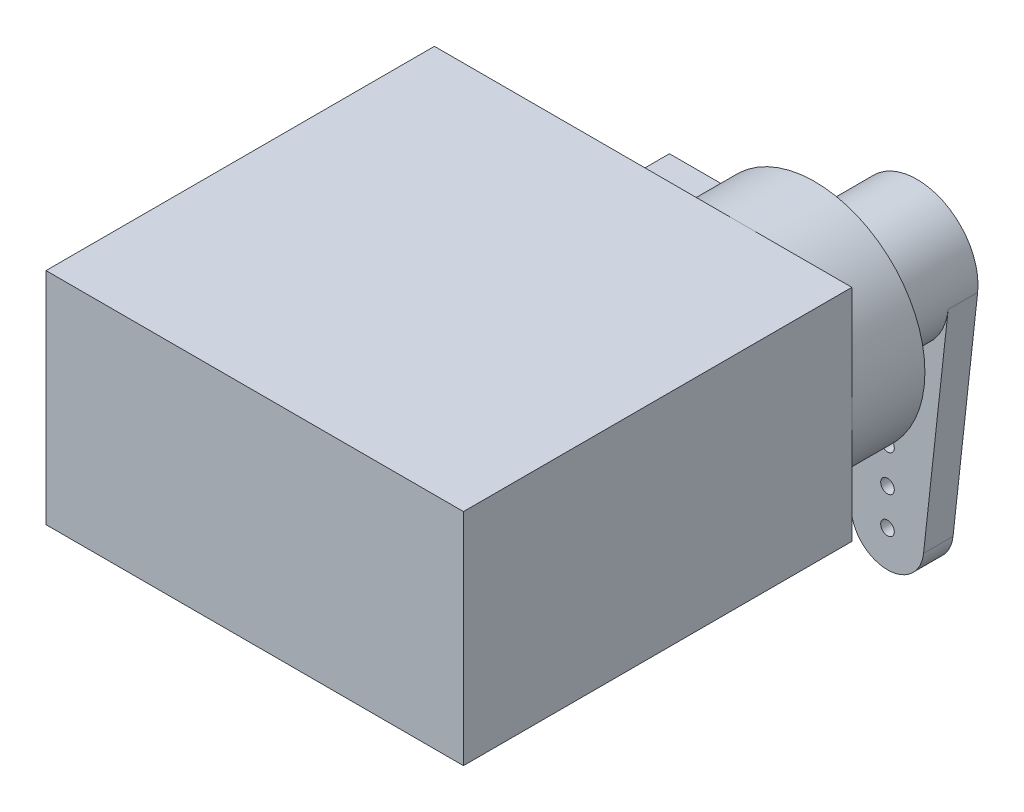
from build123d import *

# Parameters (mm, degrees)
SKETCH1_W           = 23.368
SKETCH1_H           = 21.7424
BOSS_EXTRUDE1_DEPTH = 12.319
BOSS_EXTRUDE2_DEPTH = 4.0894
SKETCH3_R           = 3.4163
BOSS_EXTRUDE3_DEPTH = 4.064
BOSS_EXTRUDE4_DEPTH = 1.651
CUT_EXTRUDE1_START  = -1.651
SKETCH5_R           = 0.381
CUT_EXTRUDE1_DEPTH  = 1.651


with BuildPart() as part:
    # Sketch1 → Boss-Extrude1 (new body)
    with BuildSketch(Plane(origin=(0, 0, 0), x_dir=(1, 0, 0), z_dir=(0, 1, 0))):
        Rectangle(SKETCH1_W, SKETCH1_H)
    extrude(amount=BOSS_EXTRUDE1_DEPTH)

    # Sketch2 → Boss-Extrude2 (add)
    with BuildSketch(Plane(origin=(0, 0, -10.8712), x_dir=(-1, 0, 0), z_dir=(0, 0, -1))):
        with BuildLine():
            Line((-0.416257508, 2.7178), (2.6162, 2.7178))
            Line((2.6162, 2.7178), (2.6162, 9.6012))
            Line((2.6162, 9.6012), (-0.416257508, 9.6012))
            ThreePointArc((-0.416257508, 9.6012), (-11.684, 6.1595), (-0.416257508, 2.7178))
        make_face()
    extrude(amount=BOSS_EXTRUDE2_DEPTH)

    # Sketch3 → Boss-Extrude3 (add)
    with BuildSketch(Plane(origin=(0, 0, -14.9606), x_dir=(-1, 0, 0), z_dir=(0, 0, -1))):
        with Locations((-5.5245, 6.1595)):
            Circle(SKETCH3_R)
    extrude(amount=BOSS_EXTRUDE3_DEPTH)

    # Sketch4 → Boss-Extrude4 (add)
    with BuildSketch(Plane(origin=(0, 0, -19.0246), x_dir=(-1, 0, 0), z_dir=(0, 0, -1))):
        with BuildLine():
            Line((-8.920321777, 5.786002808), (-7.544319644, -6.724554463))
            ThreePointArc((-7.544319644, -6.724554463), (-5.5245, -8.5344), (-3.504680356, -6.724554463))
            Line((-3.504680356, -6.724554463), (-2.128678223, 5.786002808))
            ThreePointArc((-2.128678223, 5.786002808), (-5.5245, 9.5758), (-8.920321777, 5.786002808))
        make_face()
    extrude(amount=BOSS_EXTRUDE4_DEPTH)

    # Sketch5 → Cut-Extrude1 (cut)
    with BuildSketch(Plane(origin=(0, 0, -20.6756), x_dir=(-1, 0, 0), z_dir=(0, 0, -1)).offset(CUT_EXTRUDE1_START)):
        with Locations((-5.5245, -6.5024)):
            Circle(SKETCH5_R)
        with Locations((-5.5245, -4.4704)):
            Circle(SKETCH5_R)
        with Locations((-5.5245, -2.4384)):
            Circle(SKETCH5_R)
        with Locations((-5.5245, -0.4064)):
            Circle(SKETCH5_R)
        with Locations((-5.5245, 1.6256)):
            Circle(SKETCH5_R)
    extrude(amount=CUT_EXTRUDE1_DEPTH, mode=Mode.SUBTRACT)


solid = part.part
